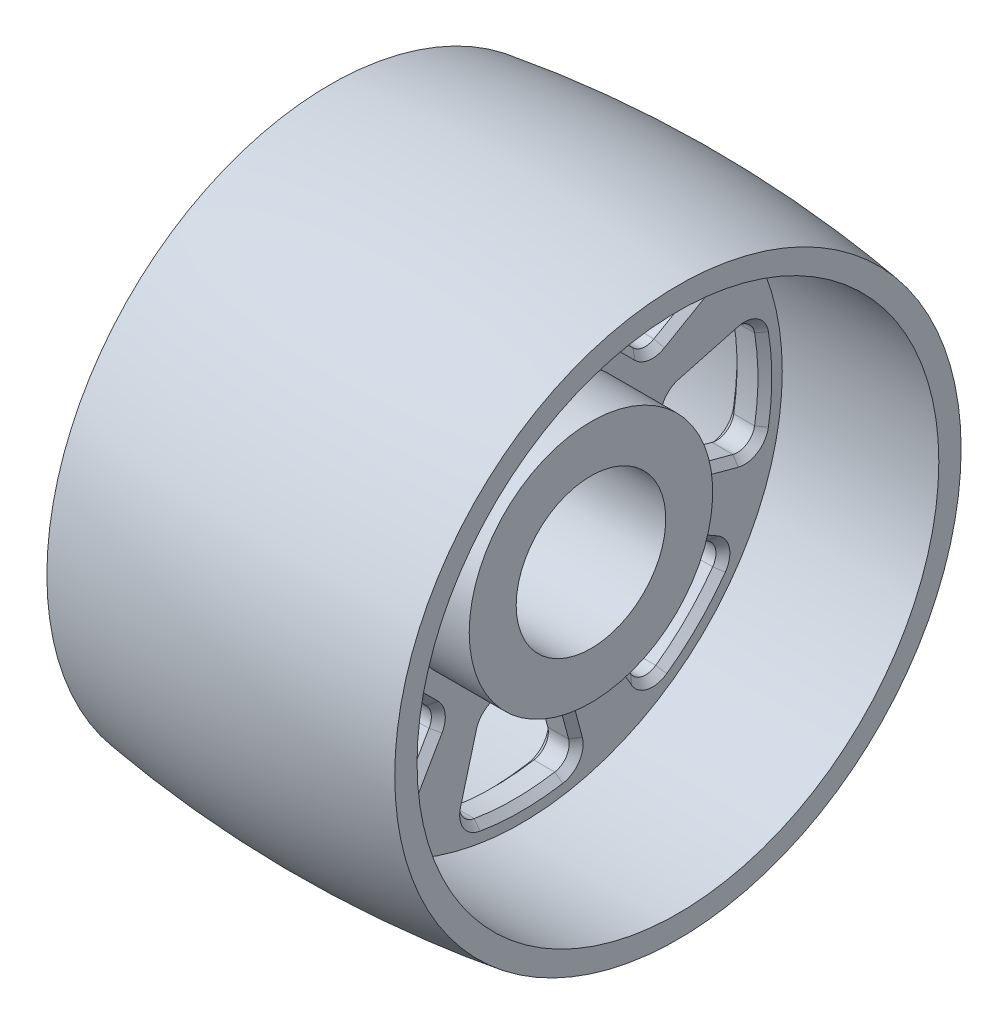
from build123d import *

# Parameters (mm, degrees)
CUT_EXTRUDE1_DEPTH           = 20
FILLET1_R                    = 10
CHAMFER1_SIZE                = 4
CIRPATTERN1_COUNT            = 8
FILLET1_OF_CIRPATTERN1_R     = 10
CHAMFER1_OF_CIRPATTERN1_SIZE = 4


with BuildPart() as part:
    # Sketch1 → Revolve1 (revolve)
    with BuildSketch(Plane.XY):
        with BuildLine():
            Line((-50, 43), (50, 43))
            Line((50, 43), (50, 70))
            Line((50, 70), (10, 70))
            Line((10, 70), (10, 150))
            Line((10, 150), (100, 150))
            Line((100, 150), (100, 162.820323028))
            ThreePointArc((100, 162.820323028), (0, 170), (-100, 162.820323028))
            Line((-100, 162.820323028), (-100, 150))
            Line((-100, 150), (-10, 150))
            Line((-10, 150), (-10, 70))
            Line((-10, 70), (-50, 70))
            Line((-50, 70), (-50, 43))
        make_face()
    revolve(axis=Axis((0, 0, 0), (1, 0, 0)))

    # Sketch2 → Cut-Extrude1 (cut)
    with BuildSketch(Plane(origin=(10, 0, 0), x_dir=(0, 0, -1), z_dir=(1, 0, 0))):
        with BuildLine():
            Line((-20, 84), (20, 84))
            Line((20, 84), (33.889496341, 135.836306037))
            ThreePointArc((33.889496341, 135.836306037), (0, 140), (-33.889496341, 135.836306037))
            Line((-33.889496341, 135.836306037), (-20, 84))
        make_face()
    cut_extrude1 = extrude(amount=-CUT_EXTRUDE1_DEPTH, mode=Mode.SUBTRACT)

    # Fillet1
    fillet1_edges = [part.edges().sort_by_distance(p)[0] for p in [
        (0, 84, 20),
        (0, 135.836306037, 33.889496341),
        (0, 135.836306037, -33.889496341),
        (0, 84, -20),
    ]]
    fillet(fillet1_edges, radius=FILLET1_R)

    # Chamfer1
    chamfer1_edges = [part.edges().sort_by_distance(p)[0] for p in [
        (-10, 108.517248378, 26.569376904),
        (10, 108.517248378, 26.569376904),
        (-10, 140, 0),
        (10, 140, 0),
        (-10, 108.517248378, -26.569376904),
        (10, 108.517248378, -26.569376904),
        (-10, 84, 0),
        (10, 84, 0),
        (10, 133.619398336, 29.904684491),
        (-10, 133.619398336, 29.904684491),
        (10, 133.619398336, -29.904684491),
        (-10, 133.619398336, -29.904684491),
        (10, 86.066466597, -18.41434441),
        (-10, 86.066466597, -18.41434441),
        (10, 86.066466597, 18.41434441),
        (-10, 86.066466597, 18.41434441),
    ]]
    chamfer(chamfer1_edges, length=CHAMFER1_SIZE)

    # CirPattern1: Cut-Extrude1 ×8 about axis
    cirpattern1_axis = Axis((0, 0, 0), (1, 0, 0))
    for i in range(1, CIRPATTERN1_COUNT):
        add(cut_extrude1.rotate(cirpattern1_axis, i * 360 / CIRPATTERN1_COUNT), mode=Mode.SUBTRACT)

    # Fillet1 of CirPattern1
    fillet1_of_cirpattern1_edges = [part.edges().sort_by_distance(p)[0] for p in [
        (0, 45.254833996, 73.539105243),
        (0, 72.087280456, 120.014265804),
        (0, 120.014265804, 72.087280456),
        (0, 73.539105243, 45.254833996),
        (0, -20, 84),
        (0, -33.889496341, 135.836306037),
        (0, 33.889496341, 135.836306037),
        (0, 20, 84),
        (0, -73.539105243, 45.254833996),
        (0, -120.014265804, 72.087280456),
        (0, -72.087280456, 120.014265804),
        (0, -45.254833996, 73.539105243),
        (0, -84, -20),
        (0, -135.836306037, -33.889496341),
        (0, -135.836306037, 33.889496341),
        (0, -84, 20),
        (0, -45.254833996, -73.539105243),
        (0, -72.087280456, -120.014265804),
        (0, -120.014265804, -72.087280456),
        (0, -73.539105243, -45.254833996),
        (0, 20, -84),
        (0, 33.889496341, -135.836306037),
        (0, -33.889496341, -135.836306037),
        (0, -20, -84),
        (0, 73.539105243, -45.254833996),
        (0, 120.014265804, -72.087280456),
        (0, 72.087280456, -120.014265804),
        (0, 45.254833996, -73.539105243),
    ]]
    fillet(fillet1_of_cirpattern1_edges, radius=FILLET1_OF_CIRPATTERN1_R)

    # Chamfer1 of CirPattern1
    chamfer1_of_cirpattern1_edges = [part.edges().sort_by_distance(p)[0] for p in [
        (-10, 57.945895623, 95.520668784),
        (10, 57.945895623, 95.520668784),
        (-10, 98.994949366, 98.994949366),
        (10, 98.994949366, 98.994949366),
        (-10, 95.520668784, 57.945895623),
        (10, 95.520668784, 57.945895623),
        (-10, 59.39696962, 59.39696962),
        (10, 59.39696962, 59.39696962),
        (10, 73.337377469, 115.628987855),
        (-10, 73.337377469, 115.628987855),
        (10, 115.628987855, 73.337377469),
        (-10, 115.628987855, 73.337377469),
        (10, 73.879089967, 47.83727436),
        (-10, 73.879089967, 47.83727436),
        (10, 47.83727436, 73.879089967),
        (-10, 47.83727436, 73.879089967),
        (-10, -26.569376904, 108.517248378),
        (10, -26.569376904, 108.517248378),
        (-10, 0, 140),
        (10, 0, 140),
        (-10, 26.569376904, 108.517248378),
        (10, 26.569376904, 108.517248378),
        (-10, 0, 84),
        (10, 0, 84),
        (10, -29.904684491, 133.619398336),
        (-10, -29.904684491, 133.619398336),
        (10, 29.904684491, 133.619398336),
        (-10, 29.904684491, 133.619398336),
        (10, 18.41434441, 86.066466597),
        (-10, 18.41434441, 86.066466597),
        (10, -18.41434441, 86.066466597),
        (-10, -18.41434441, 86.066466597),
        (-10, -95.520668784, 57.945895623),
        (10, -95.520668784, 57.945895623),
        (-10, -98.994949366, 98.994949366),
        (10, -98.994949366, 98.994949366),
        (-10, -57.945895623, 95.520668784),
        (10, -57.945895623, 95.520668784),
        (-10, -59.39696962, 59.39696962),
        (10, -59.39696962, 59.39696962),
        (10, -115.628987855, 73.337377469),
        (-10, -115.628987855, 73.337377469),
        (10, -73.337377469, 115.628987855),
        (-10, -73.337377469, 115.628987855),
        (10, -47.83727436, 73.879089967),
        (-10, -47.83727436, 73.879089967),
        (10, -73.879089967, 47.83727436),
        (-10, -73.879089967, 47.83727436),
        (-10, -108.517248378, -26.569376904),
        (10, -108.517248378, -26.569376904),
        (-10, -140, 0),
        (10, -140, 0),
        (-10, -108.517248378, 26.569376904),
        (10, -108.517248378, 26.569376904),
        (-10, -84, 0),
        (10, -84, 0),
        (10, -133.619398336, -29.904684491),
        (-10, -133.619398336, -29.904684491),
        (10, -133.619398336, 29.904684491),
        (-10, -133.619398336, 29.904684491),
        (10, -86.066466597, 18.41434441),
        (-10, -86.066466597, 18.41434441),
        (10, -86.066466597, -18.41434441),
        (-10, -86.066466597, -18.41434441),
        (-10, -57.945895623, -95.520668784),
        (10, -57.945895623, -95.520668784),
        (-10, -98.994949366, -98.994949366),
        (10, -98.994949366, -98.994949366),
        (-10, -95.520668784, -57.945895623),
        (10, -95.520668784, -57.945895623),
        (-10, -59.39696962, -59.39696962),
        (10, -59.39696962, -59.39696962),
        (10, -73.337377469, -115.628987855),
        (-10, -73.337377469, -115.628987855),
        (10, -115.628987855, -73.337377469),
        (-10, -115.628987855, -73.337377469),
        (10, -73.879089967, -47.83727436),
        (-10, -73.879089967, -47.83727436),
        (10, -47.83727436, -73.879089967),
        (-10, -47.83727436, -73.879089967),
        (-10, 26.569376904, -108.517248378),
        (10, 26.569376904, -108.517248378),
        (-10, 0, -140),
        (10, 0, -140),
        (-10, -26.569376904, -108.517248378),
        (10, -26.569376904, -108.517248378),
        (-10, 0, -84),
        (10, 0, -84),
        (10, 29.904684491, -133.619398336),
        (-10, 29.904684491, -133.619398336),
        (10, -29.904684491, -133.619398336),
        (-10, -29.904684491, -133.619398336),
        (10, -18.41434441, -86.066466597),
        (-10, -18.41434441, -86.066466597),
        (10, 18.41434441, -86.066466597),
        (-10, 18.41434441, -86.066466597),
        (-10, 95.520668784, -57.945895623),
        (10, 95.520668784, -57.945895623),
        (-10, 98.994949366, -98.994949366),
        (10, 98.994949366, -98.994949366),
        (-10, 57.945895623, -95.520668784),
        (10, 57.945895623, -95.520668784),
        (-10, 59.39696962, -59.39696962),
        (10, 59.39696962, -59.39696962),
        (10, 115.628987855, -73.337377469),
        (-10, 115.628987855, -73.337377469),
        (10, 73.337377469, -115.628987855),
        (-10, 73.337377469, -115.628987855),
        (10, 47.83727436, -73.879089967),
        (-10, 47.83727436, -73.879089967),
        (10, 73.879089967, -47.83727436),
        (-10, 73.879089967, -47.83727436),
    ]]
    chamfer(chamfer1_of_cirpattern1_edges, length=CHAMFER1_OF_CIRPATTERN1_SIZE)


solid = part.part
